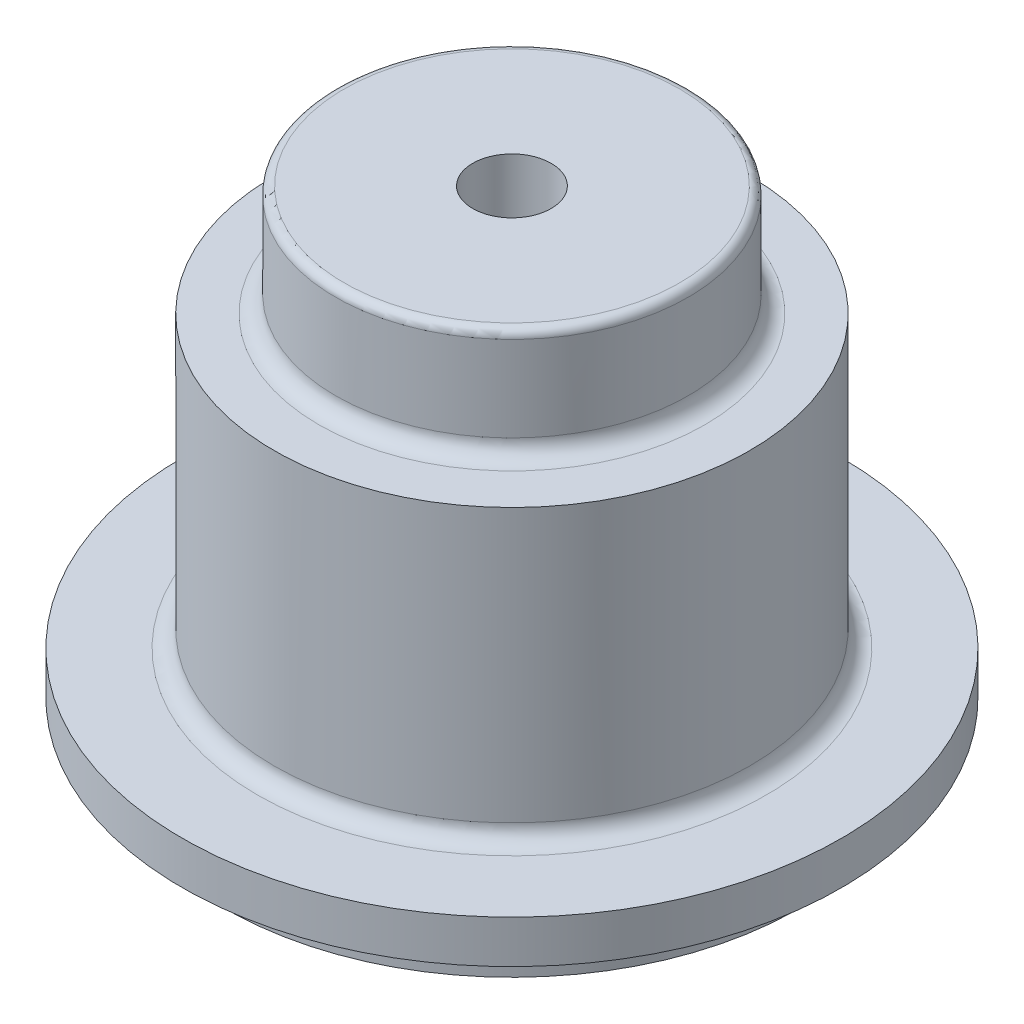
from build123d import *

# Parameters (mm, degrees)
FILLET2_R = 1.27
FILLET3_R = 0.635


with BuildPart() as part:
    # Sketch1 → Revolve4 (revolve)
    with BuildSketch(Plane.XY):
        Polygon((12.334639896, 0), (21.75, 0), (21.75, 3), (25, 3), (25, 6.25), (18.035610483, 6.25), (18.035610483, 28.23587128), (13.370385965, 28.23587128), (13.370385965, 36.611095198), (2.974741934, 36.611095198), (2.974741934, 28.23587128), (0, 28.23587128), (0, 25.3), (2.830568931, 25.3), (2.974741934, 25.3), (12.334639896, 25.3), align=None)
    revolve(axis=Axis((0, 0, 0), (0, 1, 0)))

    # Fillet2
    fillet2_edges = [part.edges().sort_by_distance(p)[0] for p in [
        (-13.370385965, 28.23587128, 0),
        (-18.035610483, 6.25, 0),
    ]]
    fillet(fillet2_edges, radius=FILLET2_R)

    # Fillet3
    fillet3_edges = [part.edges().sort_by_distance(p)[0] for p in [
        (-13.370385965, 36.611095198, 0),
    ]]
    fillet(fillet3_edges, radius=FILLET3_R)


solid = part.part
